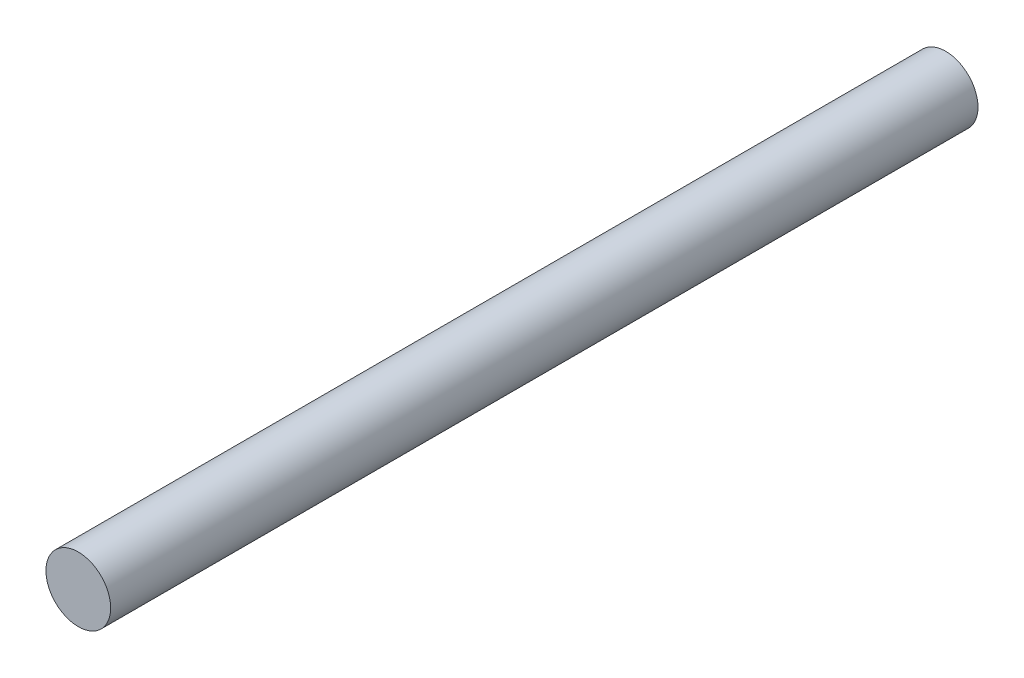
from build123d import *

# Parameters (mm, degrees)
SKETCH1_R           = 3.175
BOSS_EXTRUDE1_DEPTH = 85.09


with BuildPart() as part:
    # Sketch1 → Boss-Extrude1 (new body)
    with BuildSketch(Plane.XY):
        Circle(SKETCH1_R)
    extrude(amount=BOSS_EXTRUDE1_DEPTH)


solid = part.part
